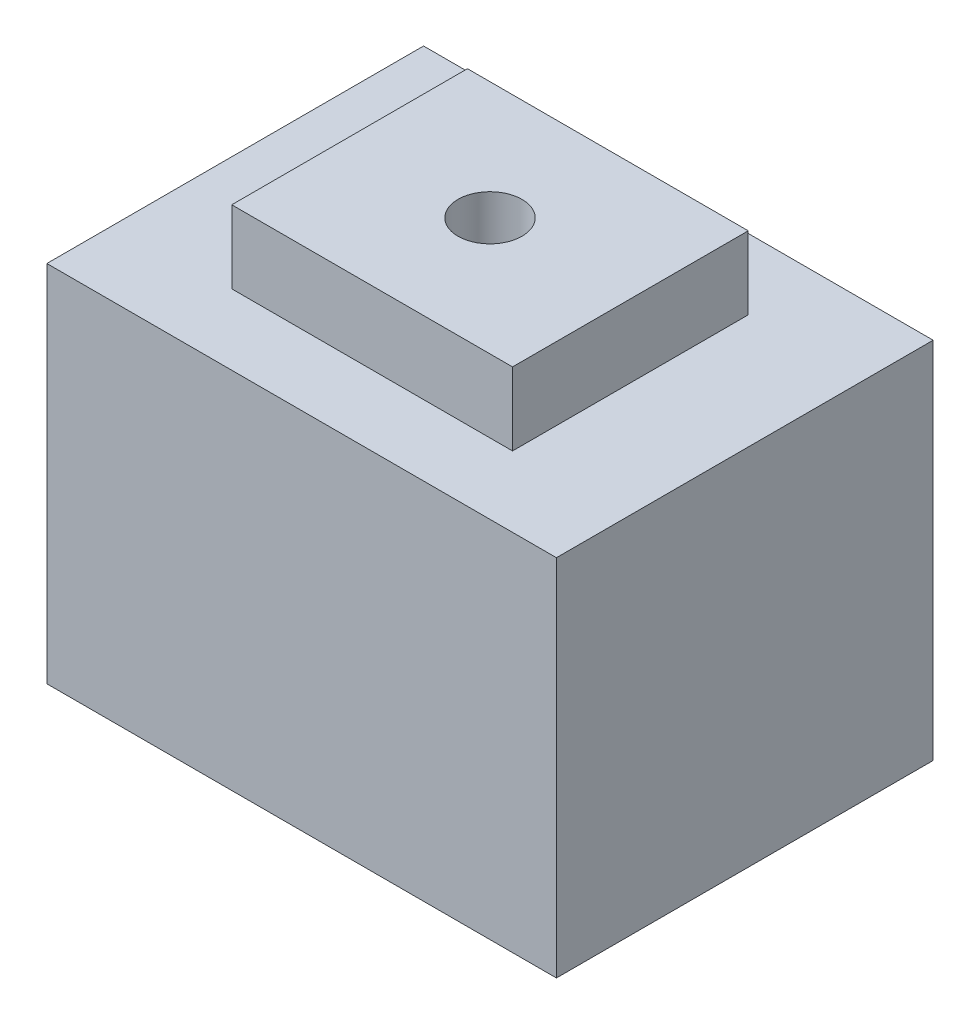
from build123d import *

# Parameters (mm, degrees)
SKETCH3_W           = 70
SKETCH3_H           = 51.746411484
BOSS_EXTRUDE4_DEPTH = 50
SKETCH5_W           = 38.568917084
SKETCH5_H           = 32.379951318
BOSS_EXTRUDE5_DEPTH = 10
SKETCH6_R           = 8.865907929
CUT_EXTRUDE1_DEPTH  = 40
SKETCH7_R           = 2.54163754
CUT_EXTRUDE2_DEPTH  = 5
SKETCH8_R           = 4.394376148
CUT_EXTRUDE3_DEPTH  = 61


with BuildPart() as part:
    # Sketch3 → Boss-Extrude4 (new body)
    with BuildSketch(Plane(origin=(0, 0, 0), x_dir=(1, 0, 0), z_dir=(0, 1, 0))):
        Rectangle(SKETCH3_W, SKETCH3_H)
    extrude(amount=BOSS_EXTRUDE4_DEPTH)

    # Sketch5 → Boss-Extrude5 (add)
    with BuildSketch(Plane(origin=(0, 50, 0), x_dir=(1, 0, 0), z_dir=(0, 1, 0))):
        Rectangle(SKETCH5_W, SKETCH5_H)
    extrude(amount=BOSS_EXTRUDE5_DEPTH)

    # Sketch6 → Cut-Extrude1 (cut)
    with BuildSketch(Plane.XZ):
        Circle(SKETCH6_R)
    extrude(amount=-CUT_EXTRUDE1_DEPTH, mode=Mode.SUBTRACT)

    # Sketch7 → Cut-Extrude2 (cut)
    with BuildSketch(Plane.XZ.offset(-40)):
        Circle(SKETCH7_R)
    extrude(amount=-CUT_EXTRUDE2_DEPTH, mode=Mode.SUBTRACT)

    # Sketch8 → Cut-Extrude3 (cut, through all)
    with BuildSketch(Plane(origin=(0, 60, 0), x_dir=(1, 0, 0), z_dir=(0, 1, 0))):
        Circle(SKETCH8_R)
    extrude(amount=-CUT_EXTRUDE3_DEPTH, mode=Mode.SUBTRACT)


solid = part.part
